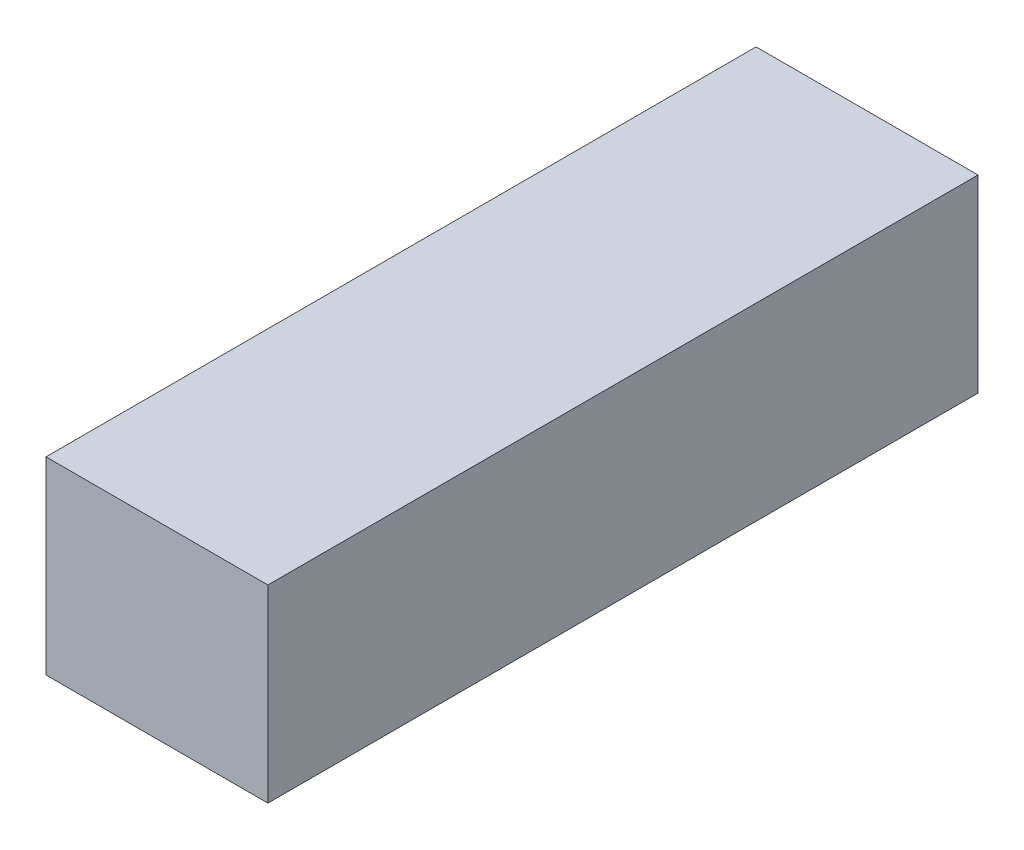
from build123d import *

# Parameters (mm, degrees)
SKETCH1_W           = 35
SKETCH1_H           = 29.8
BOSS_EXTRUDE1_DEPTH = 112


with BuildPart() as part:
    # Sketch1 → Boss-Extrude1 (new body)
    with BuildSketch(Plane.XY):
        Rectangle(SKETCH1_W, SKETCH1_H)
    extrude(amount=BOSS_EXTRUDE1_DEPTH)


solid = part.part
